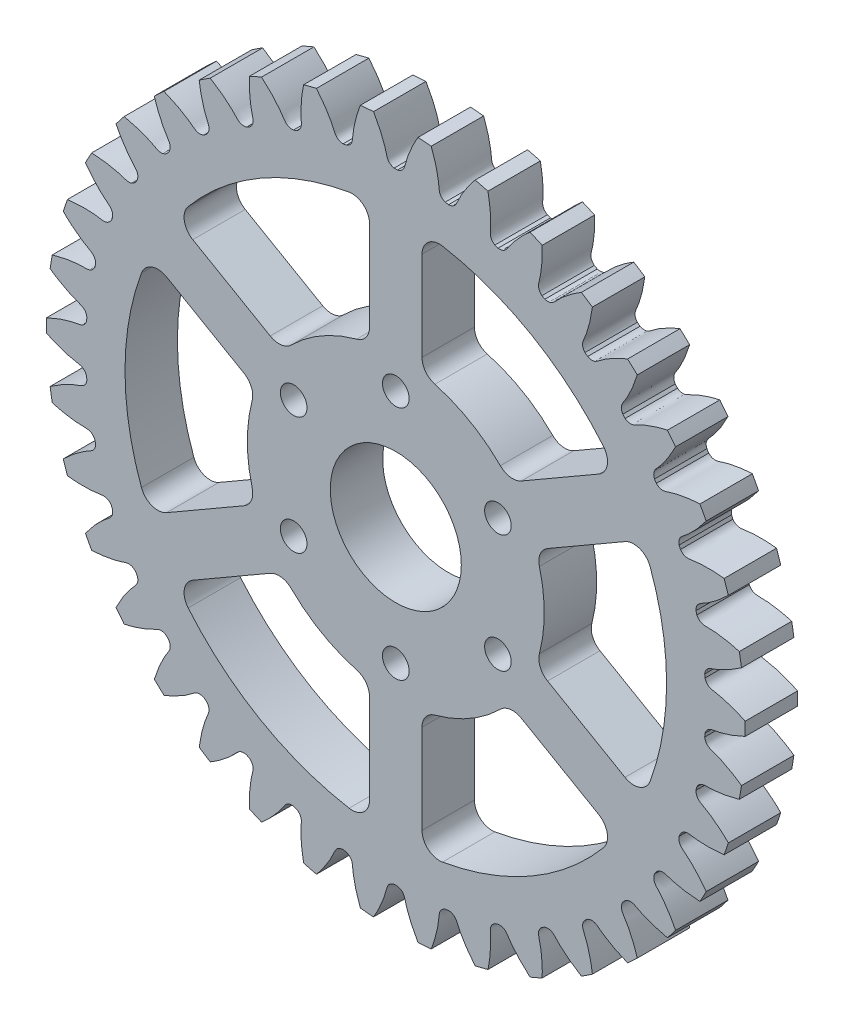
from build123d import *

# Parameters (mm, degrees)
SKETCH_1_R               = 40
EXTRUDE_1_DEPTH          = 3
CUT_EXTRUDE_1_DEPTH      = 90
PATTERN_CIRCULAR_1_COUNT = 38
SKETCH_4_R               = 1.525
CUT_EXTRUDE_2_DEPTH      = 20
SKETCH_5_R               = 7.5
CUT_EXTRUDE_3_DEPTH      = 20
CUT_EXTRUDE_4_DEPTH      = 10
FILLET_1_R               = 2


with BuildPart() as part:
    # 草图1 → 凸台-拉伸1 (new, symmetric)
    with BuildSketch(Plane.XY):
        Circle(SKETCH_1_R)
    extrude(amount=EXTRUDE_1_DEPTH, both=True)

    # 草图2 → 切除-拉伸1 (cut, symmetric)
    with BuildSketch(Plane.XY):
        with BuildLine():
            ThreePointArc((0.194695136, 35.499466106), (0, 35.5), (-0.194695136, 35.499466106))
            add(Edge.make_bspline(
                [(-0.194695136, 35.499466106), (-0.926307842, 35.673077146), (-1.002472057, 36.235277136), (-1.170331576, 36.83416526), (-1.224565972, 37.015253008), (-1.286893544, 37.2087657), (-1.357689428, 37.414517087), (-1.437508438, 37.63221947), (-1.526842441, 37.861595089), (-1.626191861, 38.1023433), (-1.73604405, 38.354150511), (-1.856879106, 38.616687543), (-1.989167653, 38.889610686), (-2.133370975, 39.172561686), (-2.289940473, 39.465168063), (-2.459317321, 39.767043341), (-2.641932082, 40.077787315), (-2.838204334, 40.396986324), (-3.048542308, 40.72421353), (-3.273342527, 41.059029212), (-3.512989459, 41.400981061), (-3.767855169, 41.749604489), (-4.038298988, 42.104422951), (-4.324667181, 42.464948263), (-4.627292626, 42.830680941), (-4.946494508, 43.201110541), (-5.282578003, 43.575716011), (-5.635834017, 43.953966042), (-6.006538766, 44.335319446), (-6.531198554, 44.853888323), (-6.941618465, 45.235607213), (-7.223628056, 45.487828232)],
                knots=[0, 0, 0, 0, 0.12148281, 0.135609443, 0.150890866, 0.167327079, 0.184918083, 0.203663876, 0.22356446, 0.244619835, 0.266829999, 0.290194954, 0.314714699, 0.340389234, 0.36721856, 0.395202675, 0.424341581, 0.454635277, 0.486083764, 0.518687041, 0.552445107, 0.587357965, 0.623425612, 0.66064805, 0.699025278, 0.738557296, 0.779244104, 0.821085703, 0.864082092, 0.908233271, 1, 1, 1, 1], degree=3))
            ThreePointArc((-7.223628056, 45.487828232), (0, 46.057825823), (7.223628056, 45.487828232))
            add(Edge.make_bspline(
                [(0.194695136, 35.499466106), (0.926307842, 35.673077146), (1.002472057, 36.235277136), (1.170331576, 36.83416526), (1.224565972, 37.015253008), (1.286893544, 37.2087657), (1.357689428, 37.414517087), (1.437508438, 37.63221947), (1.526842441, 37.861595089), (1.626191861, 38.1023433), (1.73604405, 38.354150511), (1.856879106, 38.616687543), (1.989167653, 38.889610686), (2.133370975, 39.172561686), (2.289940473, 39.465168063), (2.459317321, 39.767043341), (2.641932082, 40.077787315), (2.838204334, 40.396986324), (3.048542308, 40.72421353), (3.273342527, 41.059029212), (3.512989459, 41.400981061), (3.767855169, 41.749604489), (4.038298988, 42.104422951), (4.324667181, 42.464948263), (4.627292626, 42.830680941), (4.946494508, 43.201110541), (5.282578003, 43.575716011), (5.635834017, 43.953966042), (6.006538766, 44.335319446), (6.531198554, 44.853888323), (6.941618465, 45.235607213), (7.223628056, 45.487828232)],
                knots=[0, 0, 0, 0, 0.12148281, 0.135609443, 0.150890866, 0.167327079, 0.184918083, 0.203663876, 0.22356446, 0.244619835, 0.266829999, 0.290194954, 0.314714699, 0.340389234, 0.36721856, 0.395202675, 0.424341581, 0.454635277, 0.486083764, 0.518687041, 0.552445107, 0.587357965, 0.623425612, 0.66064805, 0.699025278, 0.738557296, 0.779244104, 0.821085703, 0.864082092, 0.908233271, 1, 1, 1, 1], degree=3))
        make_face()
    cut_extrude_1 = extrude(amount=CUT_EXTRUDE_1_DEPTH, both=True, mode=Mode.SUBTRACT)

    # 阵列(圆周)1: 切除-拉伸1 ×38 about axis
    pattern_circular_1_axis = Axis((0, 0, -3.3), (0, 0, 1))
    for i in range(1, PATTERN_CIRCULAR_1_COUNT):
        add(cut_extrude_1.rotate(pattern_circular_1_axis, i * 360 / PATTERN_CIRCULAR_1_COUNT), mode=Mode.SUBTRACT)

    # 草图4 → 切除-拉伸2 (cut, symmetric)
    with BuildSketch(Plane.XY.offset(3)):
        with Locations((0, 13.5)):
            Circle(SKETCH_4_R)
        with Locations((11.691342951, 6.75)):
            Circle(SKETCH_4_R)
        with Locations((11.691342951, -6.75)):
            Circle(SKETCH_4_R)
        with Locations((0, -13.5)):
            Circle(SKETCH_4_R)
        with Locations((-11.691342951, -6.75)):
            Circle(SKETCH_4_R)
        with Locations((-11.691342951, 6.75)):
            Circle(SKETCH_4_R)
    extrude(amount=CUT_EXTRUDE_2_DEPTH, both=True, mode=Mode.SUBTRACT)

    # 草图5 → 切除-拉伸3 (cut, symmetric)
    with BuildSketch(Plane.XY.offset(3)):
        Circle(SKETCH_5_R)
    extrude(amount=CUT_EXTRUDE_3_DEPTH, both=True, mode=Mode.SUBTRACT)

    # 草图6 → 切除-拉伸4 (cut)
    with BuildSketch(Plane.XY.offset(3)):
        with BuildLine():
            Line((-3, 16.733200531), (-3, 30.854497241))
            ThreePointArc((-3, 30.854497241), (-15.5, 26.846787517), (-25.220778432, 18.025324832))
            Line((-25.220778432, 18.025324832), (-12.991376746, 10.964676477))
            ThreePointArc((-12.991376746, 10.964676477), (-8.5, 14.722431864), (-3, 16.733200531))
        make_face()
        with BuildLine():
            ThreePointArc((25.220778432, 18.025324832), (15.5, 26.846787517), (3, 30.854497241))
            Line((3, 30.854497241), (3, 16.733200531))
            ThreePointArc((3, 16.733200531), (8.5, 14.722431864), (12.991376746, 10.964676477))
            Line((12.991376746, 10.964676477), (25.220778432, 18.025324832))
        make_face()
        with BuildLine():
            Line((-15.991376746, 5.768524054), (-28.220778432, 12.829172409))
            ThreePointArc((-28.220778432, 12.829172409), (-31, 0), (-28.220778432, -12.829172409))
            Line((-28.220778432, -12.829172409), (-15.991376746, -5.768524054))
            ThreePointArc((-15.991376746, -5.768524054), (-17, 0), (-15.991376746, 5.768524054))
        make_face()
        with BuildLine():
            ThreePointArc((28.220778432, -12.829172409), (31, 0), (28.220778432, 12.829172409))
            Line((28.220778432, 12.829172409), (15.991376746, 5.768524054))
            ThreePointArc((15.991376746, 5.768524054), (17, 0), (15.991376746, -5.768524054))
            Line((15.991376746, -5.768524054), (28.220778432, -12.829172409))
        make_face()
        with BuildLine():
            Line((-12.991376746, -10.964676477), (-25.220778432, -18.025324832))
            ThreePointArc((-25.220778432, -18.025324832), (-15.5, -26.846787517), (-3, -30.854497241))
            Line((-3, -30.854497241), (-3, -16.733200531))
            ThreePointArc((-3, -16.733200531), (-8.5, -14.722431864), (-12.991376746, -10.964676477))
        make_face()
        with BuildLine():
            ThreePointArc((3, -30.854497241), (15.5, -26.846787517), (25.220778432, -18.025324832))
            Line((25.220778432, -18.025324832), (12.991376746, -10.964676477))
            ThreePointArc((12.991376746, -10.964676477), (8.5, -14.722431864), (3, -16.733200531))
            Line((3, -16.733200531), (3, -30.854497241))
        make_face()
    extrude(amount=-CUT_EXTRUDE_4_DEPTH, mode=Mode.SUBTRACT)

    # 圆角1
    fillet_1_edges = [part.edges().sort_by_distance(p)[0] for p in [
        (15.991376746, 5.768524054, 0),
        (28.220778432, 12.829172409, 0),
        (28.220778432, -12.829172409, 0),
        (15.991376746, -5.768524054, 0),
        (3, 16.733200531, 0),
        (3, 30.854497241, 0),
        (25.220778432, 18.025324832, 0),
        (12.991376746, 10.964676477, 0),
        (-3, -16.733200531, 0),
        (-3, -30.854497241, 0),
        (-25.220778432, -18.025324832, 0),
        (-12.991376746, -10.964676477, 0),
        (-15.991376746, -5.768524054, 0),
        (-28.220778432, -12.829172409, 0),
        (-12.991376746, 10.964676477, 0),
        (-25.220778432, 18.025324832, 0),
        (-3, 30.854497241, 0),
        (-3, 16.733200531, 0),
        (12.991376746, -10.964676477, 0),
        (25.220778432, -18.025324832, 0),
        (3, -30.854497241, 0),
        (3, -16.733200531, 0),
        (-28.220778432, 12.829172409, 0),
        (-15.991376746, 5.768524054, 0),
    ]]
    fillet(fillet_1_edges, radius=FILLET_1_R)


solid = part.part
